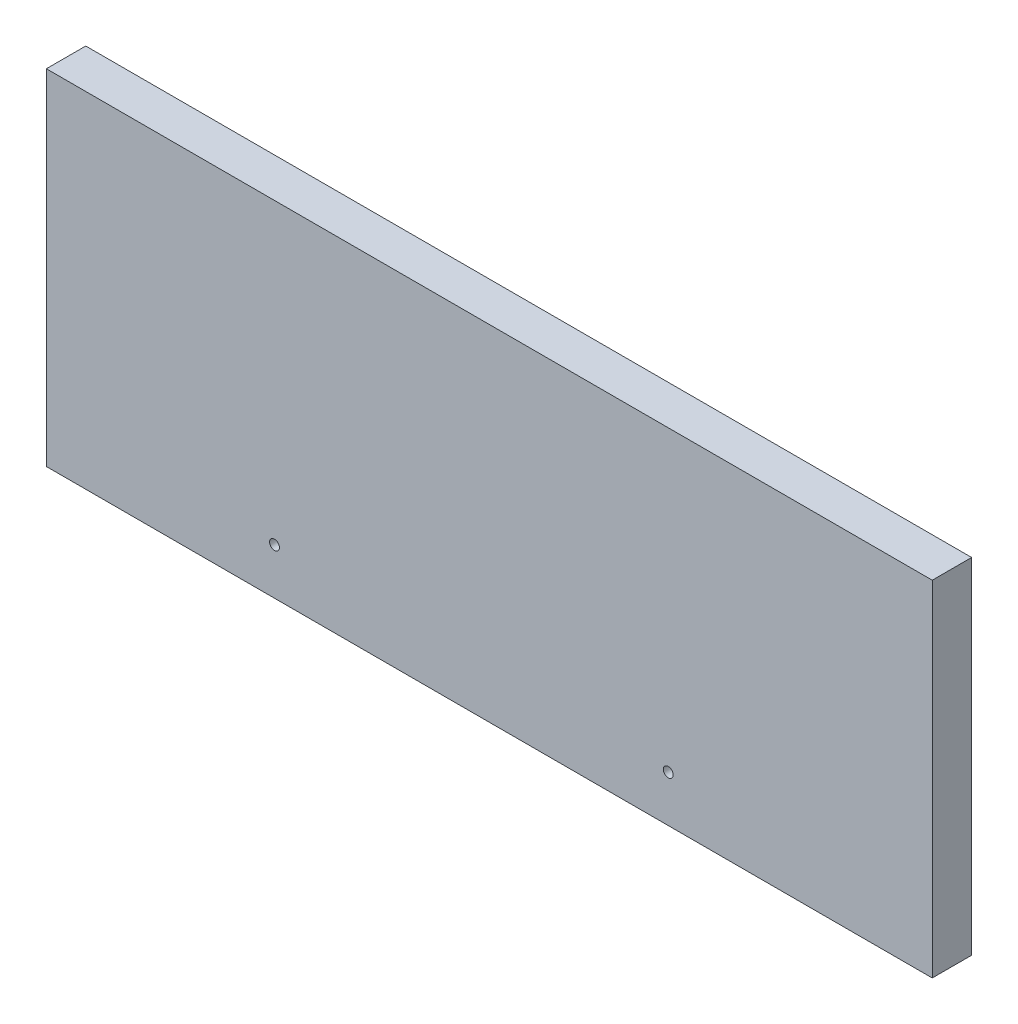
from build123d import *

# Parameters (mm, degrees)
SKETCH_1_W          = 450
SKETCH_1_H          = 175
EXTRUDE_1_DEPTH     = 20
SKETCH_2_R          = 2.5
CUT_EXTRUDE_1_DEPTH = 21


with BuildPart() as part:
    # 草图1 → 凸台-拉伸1 (new body)
    with BuildSketch(Plane.XY):
        Rectangle(SKETCH_1_W, SKETCH_1_H)
    extrude(amount=EXTRUDE_1_DEPTH)

    # 草图2 → 切除-拉伸1 (cut, through all)
    with BuildSketch(Plane.XY.offset(20)):
        with Locations((-109.12, -64)):
            Circle(SKETCH_2_R)
        with Locations((90.88, -64)):
            Circle(SKETCH_2_R)
    extrude(amount=-CUT_EXTRUDE_1_DEPTH, mode=Mode.SUBTRACT)


solid = part.part
